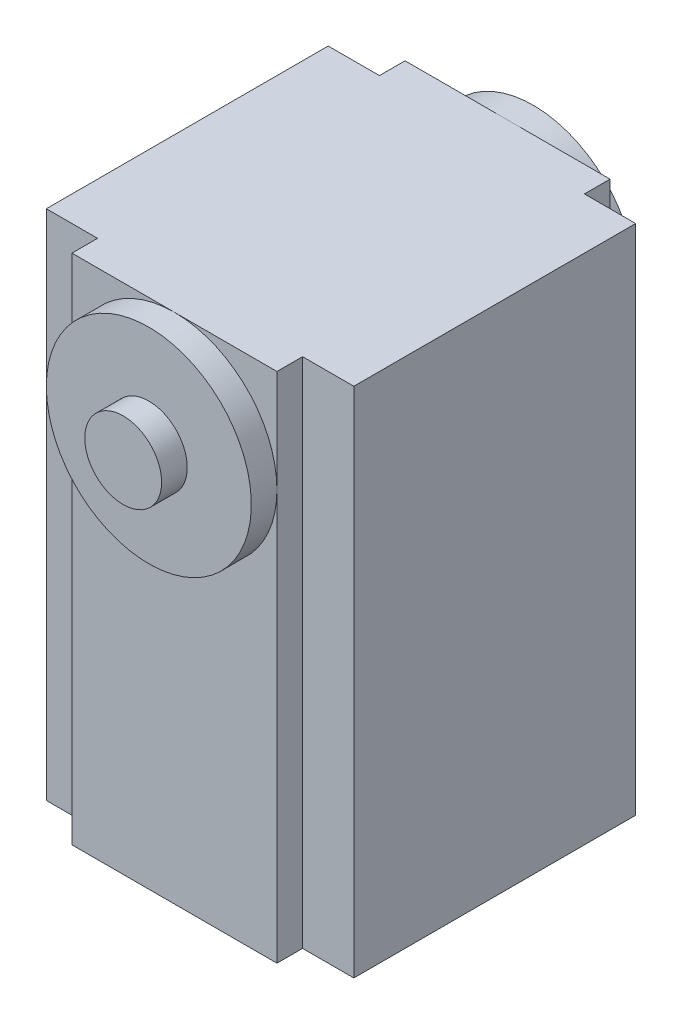
from build123d import *

# Parameters (mm, degrees)
SKETCH1_W           = 38.1
SKETCH1_H           = 63.5
BOSS_EXTRUDE1_DEPTH = 41.275
SKETCH2_R           = 12.7
BOSS_EXTRUDE2_DEPTH = 3.175
SKETCH3_R           = 4.7625
BOSS_EXTRUDE3_DEPTH = 3.175
SKETCH5_W           = 6.35
SKETCH5_H           = 63.5
CUT_EXTRUDE1_DEPTH  = 3.175


with BuildPart() as part:
    # Sketch1 → Boss-Extrude1 (new body)
    with BuildSketch(Plane.XY):
        Rectangle(SKETCH1_W, SKETCH1_H)
    extrude(amount=BOSS_EXTRUDE1_DEPTH)

    # Sketch2 → Boss-Extrude2 (add)
    with BuildSketch(Plane(origin=(0, 0, 0), x_dir=(-1, 0, 0), z_dir=(0, 0, -1))):
        with Locations((0, 19.05)):
            Circle(SKETCH2_R)
    boss_extrude2 = extrude(amount=BOSS_EXTRUDE2_DEPTH)

    # Sketch3 → Boss-Extrude3 (add)
    with BuildSketch(Plane(origin=(0, 0, -3.175), x_dir=(-1, 0, 0), z_dir=(0, 0, -1))):
        with Locations((0, 19.05)):
            Circle(SKETCH3_R)
    boss_extrude3 = extrude(amount=BOSS_EXTRUDE3_DEPTH)

    # Mirror1: Boss-Extrude2, Boss-Extrude3 across plane
    add(boss_extrude2.mirror(Plane(origin=(0, 0, 20.6375), x_dir=(1, 0, 0), z_dir=(0, 0, -1))))
    add(boss_extrude3.mirror(Plane(origin=(0, 0, 20.6375), x_dir=(1, 0, 0), z_dir=(0, 0, -1))))

    # Sketch5 → Cut-Extrude1 (cut)
    with BuildSketch(Plane.XY.offset(41.275)):
        with Locations((-15.875, 0)):
            Rectangle(SKETCH5_W, SKETCH5_H)
        with Locations((15.875, 0)):
            Rectangle(SKETCH5_W, SKETCH5_H)
    cut_extrude1 = extrude(amount=-CUT_EXTRUDE1_DEPTH, mode=Mode.SUBTRACT)

    # Mirror2: Cut-Extrude1 across plane
    add(cut_extrude1.mirror(Plane(origin=(0, 0, 20.6375), x_dir=(1, 0, 0), z_dir=(0, 0, -1))), mode=Mode.SUBTRACT)


solid = part.part
